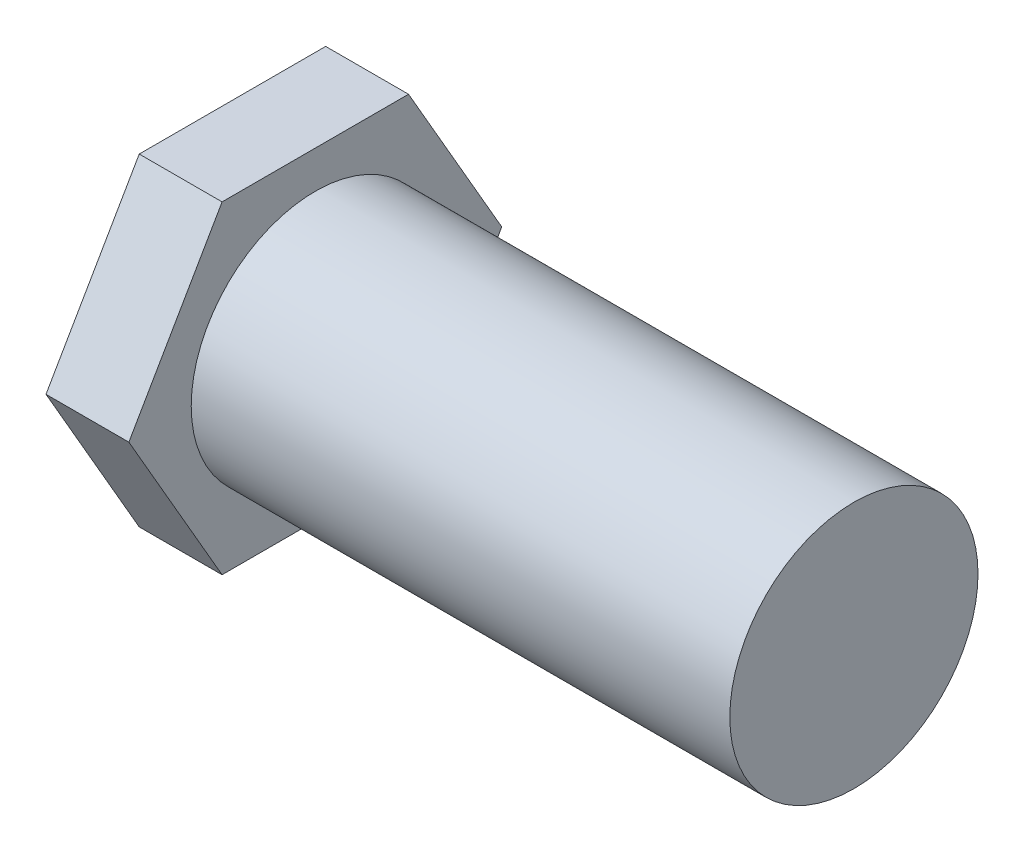
from build123d import *

# Parameters (mm, degrees)
SKETCH1_R           = 29.95
BOSS_EXTRUDE1_DEPTH = 130
BOSS_EXTRUDE2_DEPTH = 20


with BuildPart() as part:
    # Sketch1 → Boss-Extrude1 (new body)
    with BuildSketch(Plane(origin=(0, 0, 0), x_dir=(0, 0, -1), z_dir=(1, 0, 0))):
        Circle(SKETCH1_R)
    extrude(amount=BOSS_EXTRUDE1_DEPTH)

    # Sketch2 → Boss-Extrude2 (add)
    with BuildSketch(Plane.ZY):
        Polygon((45, 0), (22.5, 38.97114317), (-22.5, 38.97114317), (-45, 0), (-22.5, -38.97114317), (22.5, -38.97114317), align=None)
    extrude(amount=BOSS_EXTRUDE2_DEPTH)


solid = part.part
